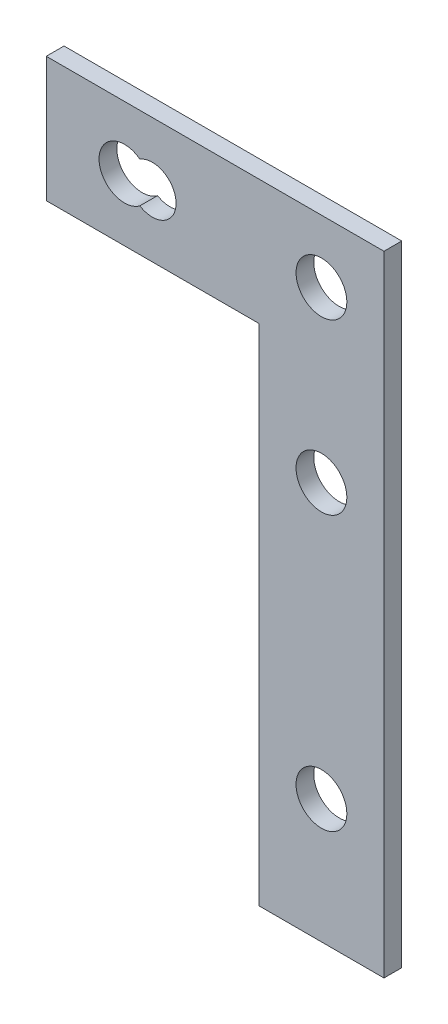
from build123d import *

# Parameters (mm, degrees)
BOSS_EXTRUDE2_DEPTH              = 1.8034
F_97_0_0059_DIAMETER_HOLE1_D     = 4.826
F_13_64_0_20313_DIAMETER_HOLE1_D = 5.159502
SKETCH7_W                        = 29.6164
SKETCH7_H                        = 12.7
CUT_EXTRUDE1_DEPTH               = 2.54


with BuildPart() as part:
    # Sketch1 → Boss-Extrude2 (new body)
    with BuildSketch(Plane.XY):
        Polygon((19.2532, -19.2532), (19.2532, 19.2532), (-19.2532, 19.2532), (-31.9532, 19.2532), (-31.9532, 31.9532), (31.9532, 31.9532), (31.9532, -31.9532), (19.2532, -31.9532), align=None)
    extrude(amount=-BOSS_EXTRUDE2_DEPTH)

    # #97 (0.0059) Diameter Hole1 (through all)
    with Locations(Plane.XY):
        with Locations((-19.3802, 25.6032), (8.4328, 25.6032), (25.6032, -19.3802), (25.6032, 8.4328)):
            Hole(F_97_0_0059_DIAMETER_HOLE1_D / 2)

    # 13/64 (0.20313) Diameter Hole1 (through all)
    with Locations(Plane.XY):
        with Locations((5.6032, 25.6032), (25.6032, 8.4328), (25.6032, -19.3802), (25.6032, 25.6032)):
            Hole(F_13_64_0_20313_DIAMETER_HOLE1_D / 2)

    # Sketch7 → Cut-Extrude1 (cut)
    with BuildSketch(Plane.XY):
        with Locations((-17.145, 25.6032)):
            Rectangle(SKETCH7_W, SKETCH7_H)
    extrude(amount=-CUT_EXTRUDE1_DEPTH, mode=Mode.SUBTRACT)


solid = part.part
